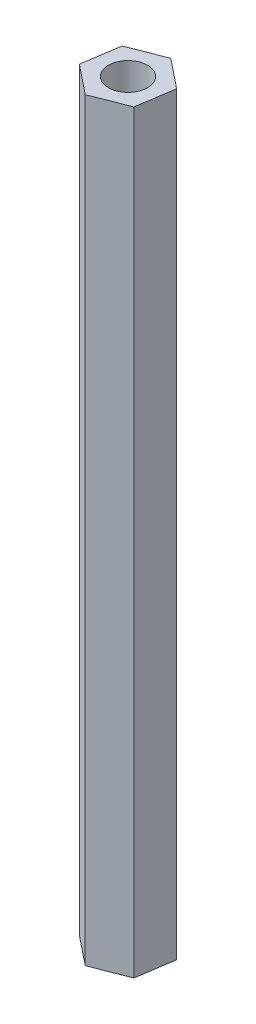
from build123d import *

# Parameters (mm, degrees)
SKETCH1_R           = 1.5
BOSS_EXTRUDE1_DEPTH = 58


with BuildPart() as part:
    # Sketch1 → Boss-Extrude1 (new body)
    with BuildSketch(Plane(origin=(0, 0, 0), x_dir=(1, 0, 0), z_dir=(0, 1, 0))):
        Polygon((2.254174087, -1.803339269), (2.688824662, 1.050502389), (0.434650576, 2.853841658), (-2.254174087, 1.803339269), (-2.688824662, -1.050502389), (-0.434650576, -2.853841658), align=None)
        Circle(SKETCH1_R, mode=Mode.SUBTRACT)
    extrude(amount=BOSS_EXTRUDE1_DEPTH)


solid = part.part
